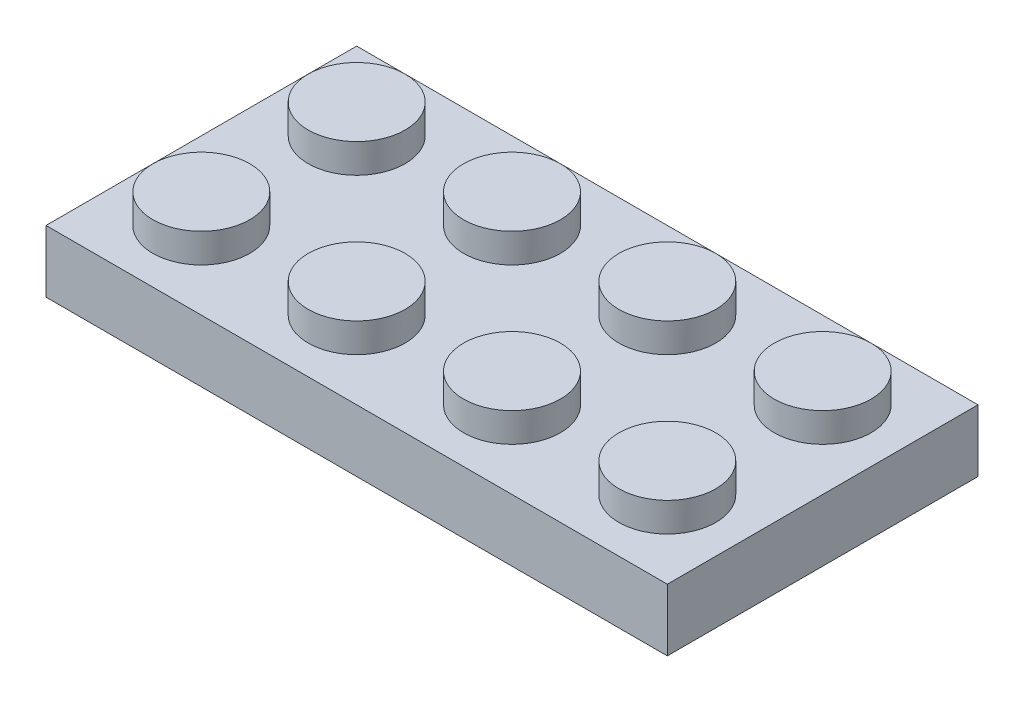
from build123d import *

# Parameters (mm, degrees)
SKETCH1_W            = 25.4
SKETCH1_H            = 12.7
BOSS_EXTRUDE1_DEPTH  = 2.54
SKETCH1_3_R          = 1.9812
BOSS_EXTRUDE2_DEPTH  = 1.1938
LPATTERN1_COUNT      = 4
LPATTERN1_PITCH      = 6.35
LPATTERN1_COUNT_DIR2 = 2
LPATTERN1_PITCH_DIR2 = 6.35
SHELL1_T             = -1.1938
SKETCH2_R            = 2.5019
SKETCH2_R_2          = 1.9812
BOSS_EXTRUDE3_DEPTH  = 1.3462
LPATTERN2_COUNT      = 3
LPATTERN2_PITCH      = 6.35
FILLET1_R            = 1.1938


with BuildPart() as part:
    # Sketch1 → Boss-Extrude1 (new body)
    with BuildSketch(Plane(origin=(0, 0, 0), x_dir=(1, 0, 0), z_dir=(0, 1, 0))):
        with Locations((12.7, 6.35)):
            Rectangle(SKETCH1_W, SKETCH1_H)
    extrude(amount=-BOSS_EXTRUDE1_DEPTH)

    # Sketch1_3 → Boss-Extrude2 (add)
    with BuildSketch(Plane(origin=(0, 0, 0), x_dir=(1, 0, 0), z_dir=(0, 1, 0))):
        with Locations((3.175, 9.525)):
            Circle(SKETCH1_3_R)
    boss_extrude2 = extrude(amount=BOSS_EXTRUDE2_DEPTH)

    # LPattern1: Boss-Extrude2 4 × 2
    with Locations(*[(i * LPATTERN1_PITCH, 0, j * LPATTERN1_PITCH_DIR2) for i in range(LPATTERN1_COUNT) for j in range(LPATTERN1_COUNT_DIR2) if (i, j) != (0, 0)]):
        add(boss_extrude2)

    # Shell1
    shell1_openings = [part.faces().sort_by_distance(p)[0] for p in [
        (12.7, -2.54, -6.35),
    ]]
    offset(amount=SHELL1_T, openings=shell1_openings, kind=Kind.INTERSECTION)

    # Sketch2 → Boss-Extrude3 (add)
    with BuildSketch(Plane.XZ.offset(1.1938)):
        with Locations((6.337930238, -6.35)):
            Circle(SKETCH2_R)
        with Locations((6.337930238, -6.35)):
            Circle(SKETCH2_R_2, mode=Mode.SUBTRACT)
    boss_extrude3 = extrude(amount=BOSS_EXTRUDE3_DEPTH)

    # LPattern2: Boss-Extrude3 ×3
    with Locations(*[(i * LPATTERN2_PITCH, 0, 0) for i in range(1, LPATTERN2_COUNT)]):
        add(boss_extrude3)

    # Fillet1
    fillet1_edges = [part.edges().sort_by_distance(p)[0] for p in [
        (1.1938, -1.8669, -1.1938),
        (1.1938, -1.8669, -11.5062),
        (24.2062, -1.8669, -11.5062),
        (24.2062, -1.8669, -1.1938),
    ]]
    fillet(fillet1_edges, radius=FILLET1_R)


solid = part.part
